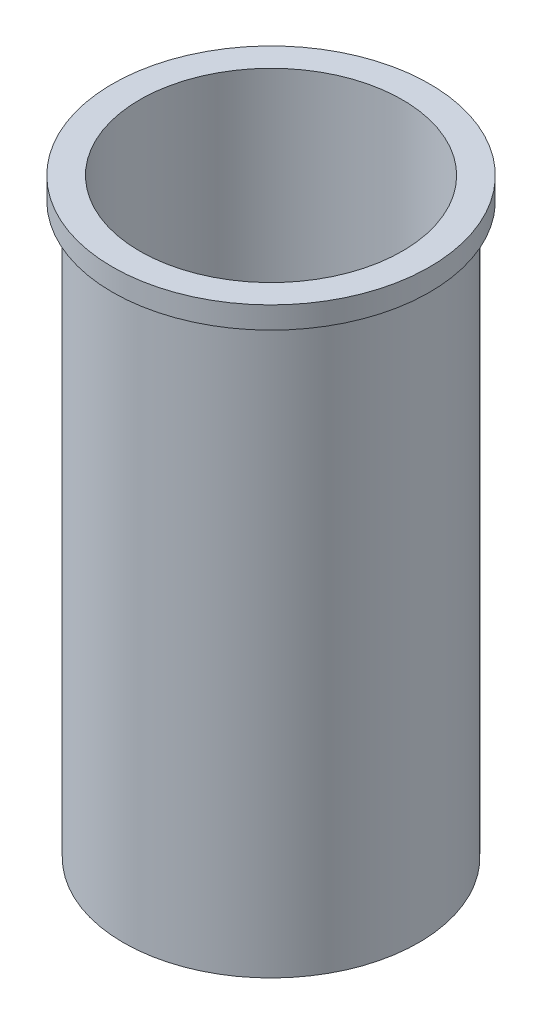
from build123d import *

# Parameters (mm, degrees)
SKETCH1_R           = 6.75
SKETCH1_R_2         = 6
BOSS_EXTRUDE1_DEPTH = 27
SKETCH2_R           = 7.25
SKETCH2_R_2         = 6.75
BOSS_EXTRUDE2_DEPTH = 1


with BuildPart() as part:
    # Sketch1 → Boss-Extrude1 (new body)
    with BuildSketch(Plane(origin=(0, 0, 0), x_dir=(1, 0, 0), z_dir=(0, 1, 0))):
        Circle(SKETCH1_R)
        Circle(SKETCH1_R_2, mode=Mode.SUBTRACT)
    extrude(amount=BOSS_EXTRUDE1_DEPTH)

    # Sketch2 → Boss-Extrude2 (add)
    with BuildSketch(Plane(origin=(0, 27, 0), x_dir=(1, 0, 0), z_dir=(0, 1, 0))):
        Circle(SKETCH2_R)
        Circle(SKETCH2_R_2, mode=Mode.SUBTRACT)
    extrude(amount=-BOSS_EXTRUDE2_DEPTH)


solid = part.part
